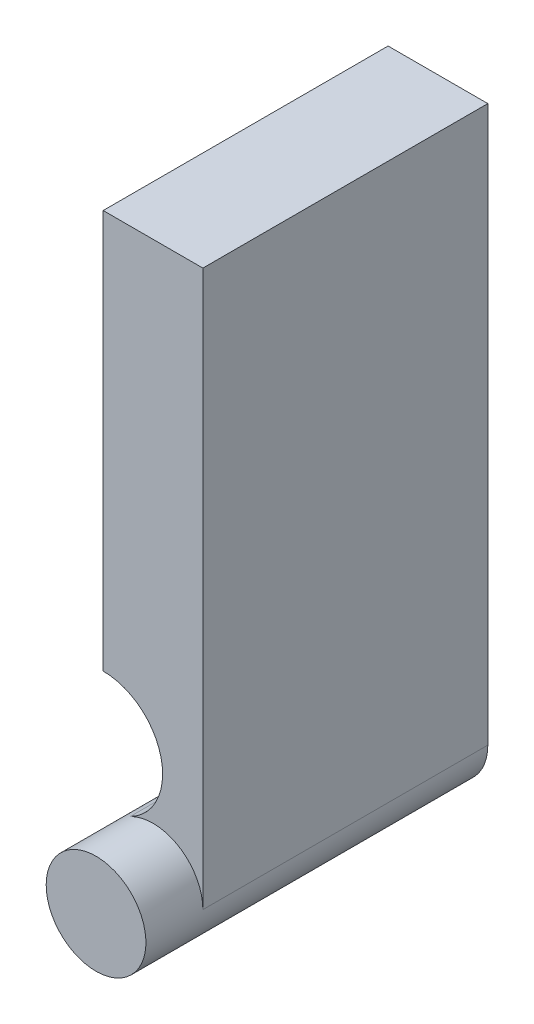
from build123d import *

# Parameters (mm, degrees)
DODANIE_WYCI_GNI_CIE1_DEPTH = 10
SZKIC2_R                    = 1.75
DODANIE_WYCI_GNI_CIE2_DEPTH = 12


with BuildPart() as part:
    # Szkic1 → Dodanie-wyciągnięcie1 (new body)
    with BuildSketch(Plane.XY):
        with BuildLine():
            Line((1.75, 0), (1.75, 19.5))
            Line((1.75, 19.5), (-1.75, 19.5))
            Line((-1.75, 19.5), (-1.75, 5.5))
            ThreePointArc((-1.75, 5.5), (0.277964608, 3.903301802), (-0.798314607, 1.557303371))
            ThreePointArc((-0.798314607, 1.557303371), (-0.912537517, -1.493243209), (1.75, 0))
        make_face()
    extrude(amount=DODANIE_WYCI_GNI_CIE1_DEPTH)

    # Szkic2 → Dodanie-wyciągnięcie2 (add)
    with BuildSketch(Plane(origin=(0, 0, 0), x_dir=(-1, 0, 0), z_dir=(0, 0, -1))):
        Circle(SZKIC2_R)
    extrude(amount=-DODANIE_WYCI_GNI_CIE2_DEPTH)


solid = part.part
